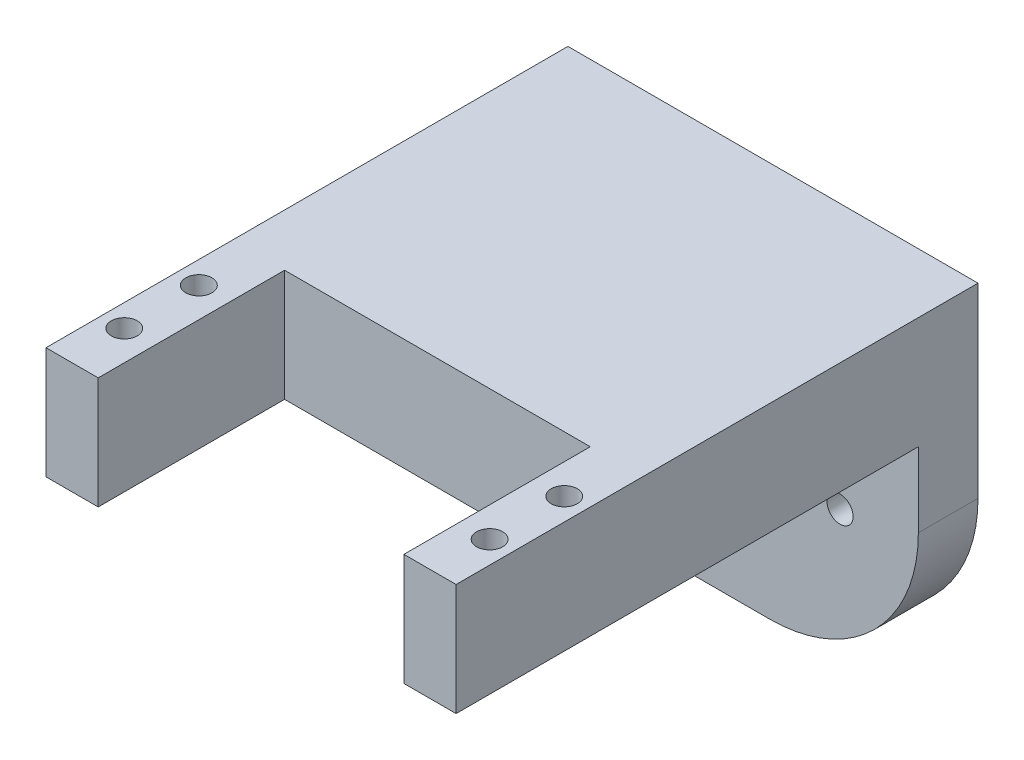
from build123d import *

# Parameters (mm, degrees)
SKETCH1_W           = 55
SKETCH1_H           = 15
BOSS_EXTRUDE1_DEPTH = 70
SKETCH2_W           = 41
SKETCH2_H           = 15
CUT_EXTRUDE1_DEPTH  = 25
SKETCH3_R           = 1.75
CUT_EXTRUDE2_DEPTH  = 16
SKETCH4_W           = 55
SKETCH4_H           = 8
BOSS_EXTRUDE2_DEPTH = 30
FILLET1_R           = 20
CUT_EXTRUDE3_DEPTH  = 3
SKETCH6_R           = 1.75
CUT_EXTRUDE4_DEPTH  = 68


with BuildPart() as part:
    # Sketch1 → Boss-Extrude1 (new body)
    with BuildSketch(Plane.XY):
        Rectangle(SKETCH1_W, SKETCH1_H)
    extrude(amount=BOSS_EXTRUDE1_DEPTH)

    # Sketch2 → Cut-Extrude1 (cut)
    with BuildSketch(Plane.XY.offset(70)):
        Rectangle(SKETCH2_W, SKETCH2_H)
    extrude(amount=-CUT_EXTRUDE1_DEPTH, mode=Mode.SUBTRACT)

    # Sketch3 → Cut-Extrude2 (cut, through all)
    with BuildSketch(Plane(origin=(0, 7.5, 0), x_dir=(1, 0, 0), z_dir=(0, 1, 0))):
        with Locations((-24.5, -62.5)):
            Circle(SKETCH3_R)
        with Locations((24.5, -62.5)):
            Circle(SKETCH3_R)
        with Locations((-24.5, -52.5)):
            Circle(SKETCH3_R)
        with Locations((24.5, -52.5)):
            Circle(SKETCH3_R)
    extrude(amount=-CUT_EXTRUDE2_DEPTH, mode=Mode.SUBTRACT)

    # Sketch4 → Boss-Extrude2 (add)
    with BuildSketch(Plane(origin=(0, -7.5, 0), x_dir=(1, 0, 0), z_dir=(0, 1, 0))):
        with Locations((0, -4)):
            Rectangle(SKETCH4_W, SKETCH4_H)
    extrude(amount=-BOSS_EXTRUDE2_DEPTH)

    # Fillet1
    fillet1_edges = [part.edges().sort_by_distance(p)[0] for p in [
        (-27.5, -37.5, 4),
        (27.5, -37.5, 4),
    ]]
    fillet(fillet1_edges, radius=FILLET1_R)

    # Sketch5 → Cut-Extrude3 (cut)
    with BuildSketch(Plane(origin=(0, 0, 0), x_dir=(-1, 0, 0), z_dir=(0, 0, -1))):
        with BuildLine():
            Line((-17.477732777, -22.657399367), (-3.39236806, -25.189589478))
            ThreePointArc((-3.39236806, -25.189589478), (0, -26.2), (3.39236806, -25.189589478))
            Line((3.39236806, -25.189589478), (17.477732777, -22.657399367))
            ThreePointArc((17.477732777, -22.657399367), (19.7, -20), (17.477732777, -17.342600633))
            Line((17.477732777, -17.342600633), (3.39236806, -14.810410522))
            ThreePointArc((3.39236806, -14.810410522), (0, -13.8), (-3.39236806, -14.810410522))
            Line((-3.39236806, -14.810410522), (-17.477732777, -17.342600633))
            ThreePointArc((-17.477732777, -17.342600633), (-19.7, -20), (-17.477732777, -22.657399367))
        make_face()
    extrude(amount=-CUT_EXTRUDE3_DEPTH, mode=Mode.SUBTRACT)

    # Sketch6 → Cut-Extrude4 (cut, through all)
    with BuildSketch(Plane(origin=(0, 0, 3), x_dir=(-1, 0, 0), z_dir=(0, 0, -1))):
        with Locations((0, -20)):
            Circle(SKETCH6_R)
        with Locations((17, -20)):
            Circle(SKETCH6_R)
        with Locations((-17, -20)):
            Circle(SKETCH6_R)
    extrude(amount=-CUT_EXTRUDE4_DEPTH, mode=Mode.SUBTRACT)


solid = part.part
